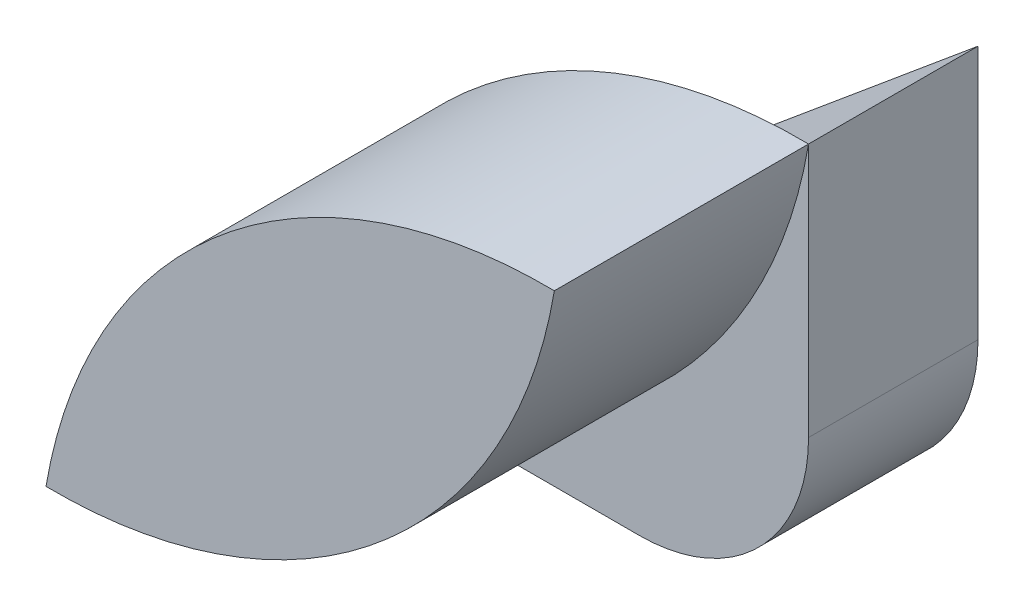
from build123d import *

# Parameters (mm, degrees)
BOSS_EXTRUDE1_DEPTH = 10
BOSS_EXTRUDE2_DEPTH = 15


with BuildPart() as part:
    # Sketch1 → Boss-Extrude1 (new body)
    with BuildSketch(Plane.XY):
        with BuildLine():
            Line((-30, -25), (0, 0))
            Line((0, 0), (0, -15))
            ThreePointArc((0, -15), (-2.928932188, -22.071067812), (-10, -25))
            Line((-10, -25), (-30, -25))
        make_face()
    extrude(amount=BOSS_EXTRUDE1_DEPTH)

    # Sketch3 → Boss-Extrude2 (add)
    with BuildSketch(Plane.XY.offset(10)):
        with BuildLine():
            ThreePointArc((-30, -25), (-19.624638361, -6.950433967), (0, 0))
            ThreePointArc((0, 0), (-10.375361639, -18.049566033), (-30, -25))
        make_face()
    extrude(amount=BOSS_EXTRUDE2_DEPTH)


solid = part.part
